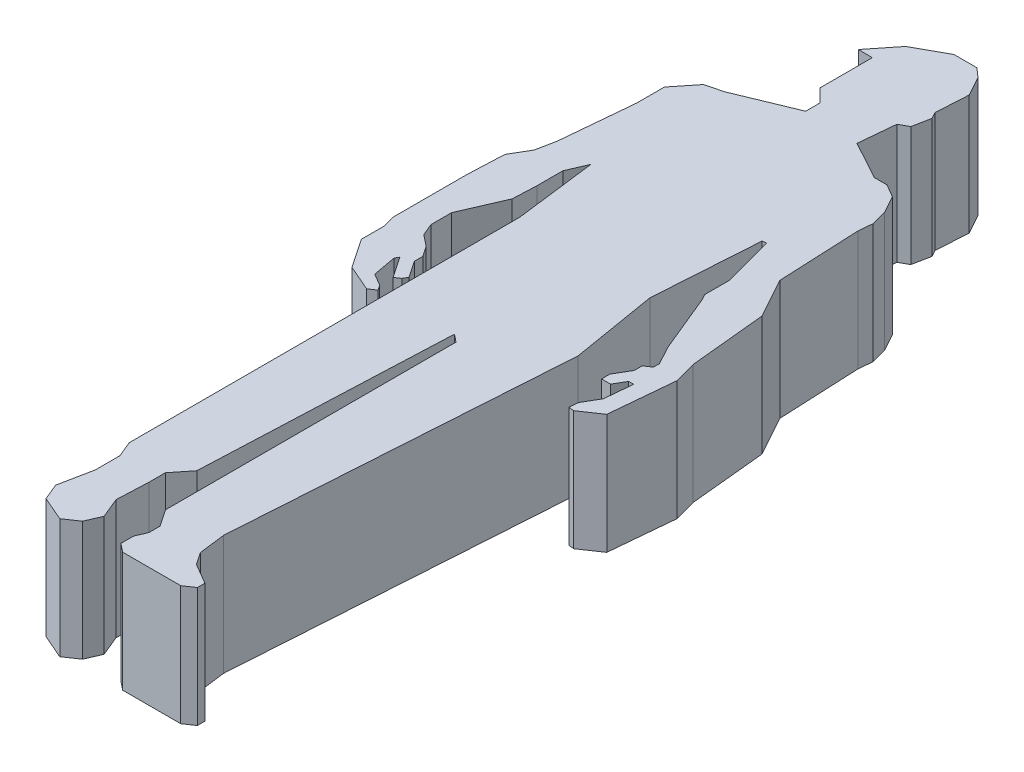
from build123d import *

# Parameters (mm, degrees)
BOSS_EXTRUDE1_DEPTH = 250


with BuildPart() as part:
    # Sketch1 → Boss-Extrude1 (new body)
    with BuildSketch(Plane(origin=(0, 0, 0), x_dir=(1, 0, 0), z_dir=(0, 1, 0))):
        Polygon((578.701410648, 1825.287545316), (531.134778167, 1825.287545316), (465.950874397, 1789.465760361), (421.907696174, 1734.264976989), (451.269814989, 1734.264976989), (451.269814989, 1624.450652619), (478.576585488, 1597.143882121), (478.576585488, 1567.488142118), (359.072761909, 1518.159782508), (323.250976955, 1508.763904487), (287.147809461, 1463.514601229), (287.147809461, 1405.715106095), (273.107994721, 1253.858431719), (265.025038466, 1213.430529779), (242.367567897, 1174.724017557), (239.063353439, 1097.310993114), (239.063353439, 944.824114781), (245.891381344, 918.792258395), (245.891381344, 871.122618446), (287.147809461, 810.289637344), (341.161869432, 786.892336921), (355.466219294, 796.593429505), (348.314044363, 807.139376943), (323.250976955, 821.810440791), (314.154839447, 871.122618446), (318.702908201, 878.892235901), (348.314044363, 835.23034444), (359.072761909, 842.52681831), (364.624616217, 852.011236086), (341.161869432, 886.607271102), (341.161869432, 904.30284394), (326.560938876, 925.832049766), (302.757550724, 944.824114781), (292.128472658, 970.574321762), (292.128472658, 1013.676908453), (330.421956406, 1102.079693826), (332.551821838, 1151.979398219), (332.551821838, 1205.807797227), (350.275497983, 1246.723958017), (371.616569608, 1076.785889831), (371.616569608, 895.455057521), (371.616569608, 260.080879685), (385.440948916, 226.589675052), (385.440948916, 175.377140283), (371.616569608, 106.232803304), (385.847432355, 71.756844149), (436.588755582, 49.777196922), (464.923200239, 68.993384557), (478.576585488, 100.513036666), (460.98809069, 143.123259181), (463.814884827, 209.35100752), (463.814884827, 243.335277368), (493.037068607, 279.960414373), (515.088477789, 796.593429505), (531.134778167, 783.790530267), (531.134778167, 176.23713335), (554.918094408, 141.168415737), (554.918094408, 117.677057814), (545.298983692, 95.470768472), (545.298983692, 68.993384557), (562.942285845, 54.916281775), (684.351522986, 54.916281775), (705.108339961, 68.993384557), (705.108339961, 84.753210612), (662.256489638, 109.837220557), (645.00906552, 135.268705377), (637.979365683, 191.245913613), (683.682414799, 886.607271102), (653.632777579, 1066.724980903), (668.086506196, 1286.63513014), (676.572054292, 1288.050802381), (705.072909907, 1181.809528206), (705.072909907, 1129.77568395), (711.847377196, 1117.44837462), (762.510134993, 994.711812576), (782.850389521, 957.699218271), (782.850389521, 944.824114781), (768.84840262, 935.328082274), (768.84840262, 918.792258395), (750.008410059, 886.607271102), (750.008410059, 869.309253594), (768.84840262, 869.309253594), (782.850389521, 893.22931455), (793.214576246, 893.22931455), (787.8523174, 835.23034444), (768.84840262, 802.765323358), (767.094099882, 783.790530267), (778.35036001, 782.749839711), (819.535342519, 810.681156566), (831.937446607, 944.824114781), (819.535342519, 991.054844082), (803.815773154, 1150.671476587), (757.864939322, 1234.286928314), (750.008410059, 1405.715106095), (752.680318314, 1434.614853662), (743.956821075, 1467.133016429), (724.062751494, 1503.333700421), (697.028330439, 1519.15872738), (670.629087918, 1519.15872738), (590.46447955, 1562.891823116), (597.529835452, 1639.311738223), (616.253387999, 1649.601258091), (623.646904415, 1686.580841707), (616.253387999, 1700.034617481), (620.176367687, 1767.839414568), (597.529835452, 1808.892813111), align=None)
    extrude(amount=BOSS_EXTRUDE1_DEPTH)


solid = part.part
